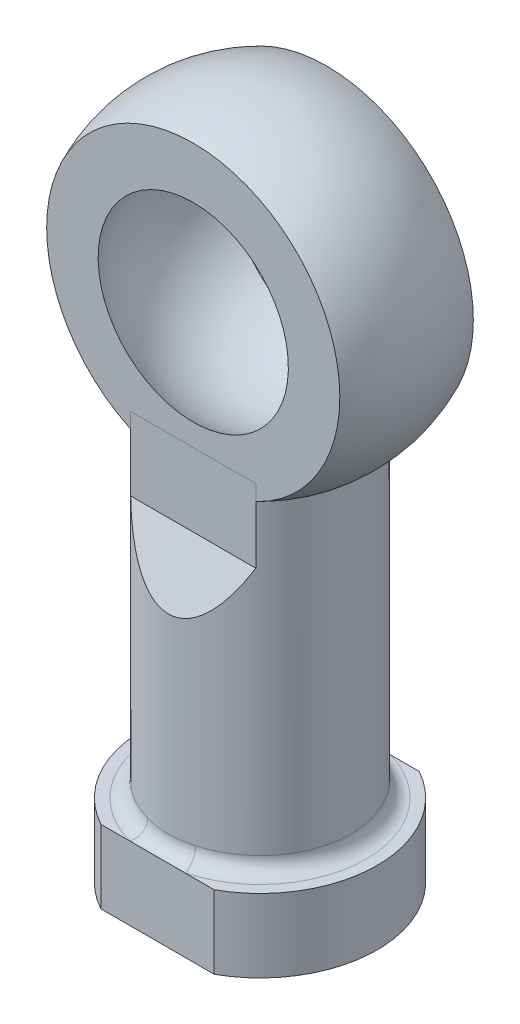
from build123d import *

# Parameters (mm, degrees)
SKETCH5_R                 = 6.25
SKETCH5_R_2               = 3.4
EXTRUDERODHOLE_DEPTH      = 3
EXTRUDERODHOLE_DEPTH_BACK = 25
SKETCH7_R                 = 3.4
BOSS_EXTRUDE1_DEPTH       = 5
FILLET1_R                 = 1
CUT_EXTRUDE1_DEPTH        = 12
CUT_EXTRUDE1_DEPTH_BACK   = 12


with BuildPart() as part:
    # Sketch3 → Revolve2 (revolve)
    with BuildSketch(Plane(origin=(0, 0, 0), x_dir=(0, 0, -1), z_dir=(1, 0, 0))):
        with BuildLine():
            Line((-4.56, 10.01031468), (-4.56, 0))
            Line((-4.56, 0), (4.56, 0))
            Line((4.56, 0), (4.56, 10.01031468))
            ThreePointArc((4.56, 10.01031468), (0, 11), (-4.56, 10.01031468))
        make_face()
    revolve(axis=Axis((0, 0, 8.146649187), (0, 0, -1)))

    # Sketch2 → Cut-Revolve2 (revolve, cut)
    with BuildSketch(Plane(origin=(0, 0, 0), x_dir=(0, 0, -1), z_dir=(1, 0, 0))):
        with BuildLine():
            Line((0, 7.938), (0, -7.938))
            ThreePointArc((0, -7.938), (7.938, 0), (0, 7.938))
        make_face()
    revolve(axis=Axis((0, 15.474361319, 0), (0, -1, 0)), mode=Mode.SUBTRACT)


with BuildPart() as body_2:
    # Sketch5 → ExtrudeRodHole (new body, two sides)
    with BuildSketch(Plane(origin=(0, -11, 0), x_dir=(-1, 0, 0), z_dir=(0, 1, 0))) as extruderodhole_sk:
        Circle(SKETCH5_R)
        Circle(SKETCH5_R_2, mode=Mode.SUBTRACT)
    extrude(amount=EXTRUDERODHOLE_DEPTH)
    extrude(extruderodhole_sk.sketch, amount=-EXTRUDERODHOLE_DEPTH_BACK)

    # Sketch7 → Boss-Extrude1 (add)
    with BuildSketch(Plane.XZ.offset(36)):
        with BuildLine():
            Line((-3.872983346, 7), (3.872983346, 7))
            ThreePointArc((3.872983346, 7), (8, 0), (3.872983346, -7))
            Line((3.872983346, -7), (-3.872983346, -7))
            ThreePointArc((-3.872983346, -7), (-8, 0), (-3.872983346, 7))
        make_face()
        Circle(SKETCH7_R, mode=Mode.SUBTRACT)
    extrude(amount=-BOSS_EXTRUDE1_DEPTH)

    # Fillet1
    fillet1_edges = [body_2.edges().sort_by_distance(p)[0] for p in [
        (6.25, -31, 0),
    ]]
    fillet(fillet1_edges, radius=FILLET1_R)

    # Sketch8 → Cut-Extrude1 (cut, two sides)
    with BuildSketch(Plane(origin=(0, 0, 0), x_dir=(0, 0, -1), z_dir=(1, 0, 0))) as cut_extrude1_sk:
        Polygon((-4.56, 0), (-4.56, -13), (-6.25, -17), (-14.338899791, -17), (-14.338899791, 16.981131473), (14.338899791, 16.981131473), (14.338899791, -17), (6.25, -17), (4.56, -13), (4.56, 0), (4.56, 14.718656898), (-4.56, 14.718656898), align=None)
    extrude(amount=CUT_EXTRUDE1_DEPTH, mode=Mode.SUBTRACT)
    extrude(cut_extrude1_sk.sketch, amount=-CUT_EXTRUDE1_DEPTH_BACK, mode=Mode.SUBTRACT)


solid = Compound([part.part, body_2.part])
